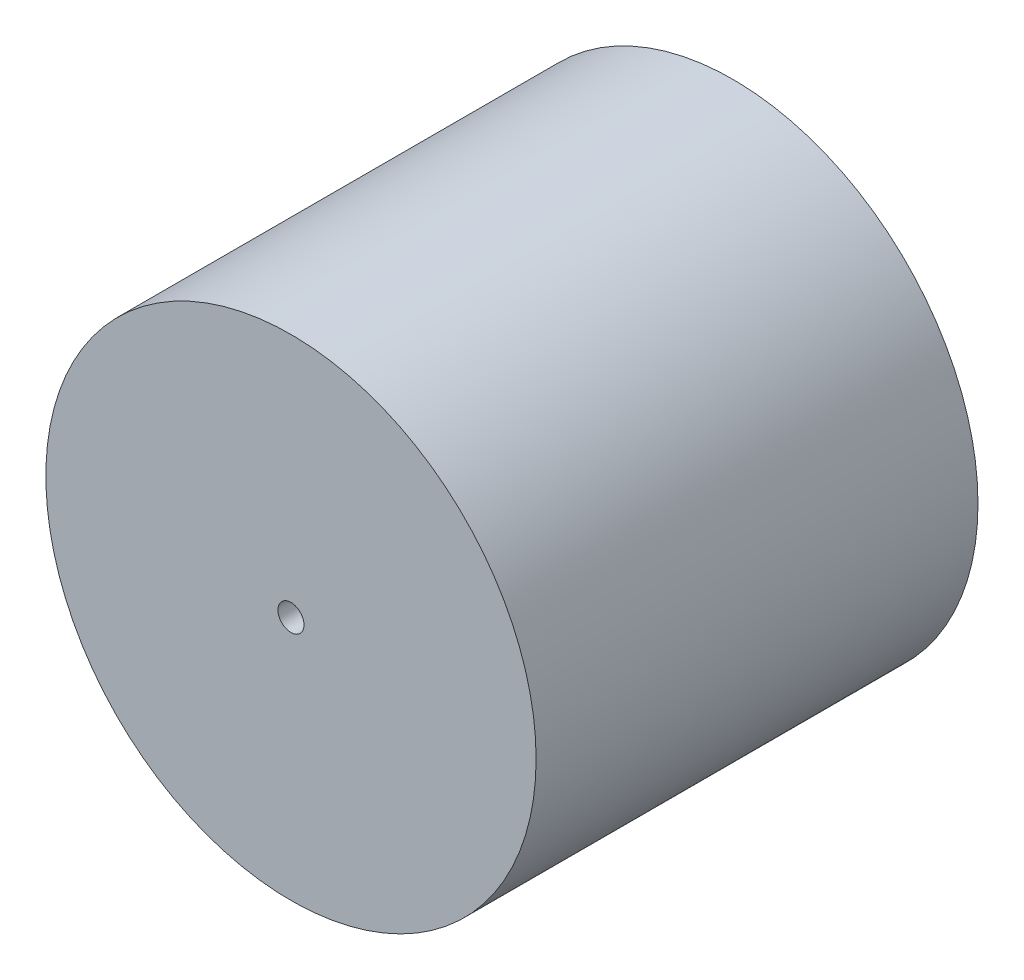
from build123d import *

# Parameters (mm, degrees)
SKETCH1_R                  = 38
BOSS_EXTRUDE1_DEPTH        = 68.5
SKETCH3_R                  = 20.5
CUT_EXTRUDE1_DEPTH         = 2
SKETCH4_R                  = 11
BOSS_EXTRUDE3_DEPTH        = 6.35
CHAMFER1_SIZE              = 4.35
CHAMFER1_SIZE2             = 3.916757593
F_10_32_TAPPED_HOLE1_D     = 4.0386
F_10_32_TAPPED_HOLE1_DEPTH = 5.6
F_10_32_TAPPED_HOLE1_TIP   = 1.213317848
F_10_32_TAPPED_HOLE2_D     = 4.0386
F_10_32_TAPPED_HOLE2_DEPTH = 13
F_10_32_TAPPED_HOLE2_TIP   = 1.213317848


with BuildPart() as part:
    # Sketch1 → Boss-Extrude1 (new body)
    with BuildSketch(Plane.XY):
        Circle(SKETCH1_R)
    extrude(amount=BOSS_EXTRUDE1_DEPTH)

    # Sketch3 → Cut-Extrude1 (cut)
    with BuildSketch(Plane(origin=(0, 0, 0), x_dir=(-1, 0, 0), z_dir=(0, 0, -1))):
        Circle(SKETCH3_R)
    extrude(amount=-CUT_EXTRUDE1_DEPTH, mode=Mode.SUBTRACT)

    # Sketch4 → Boss-Extrude3 (add)
    with BuildSketch(Plane.XY.offset(2)):
        Circle(SKETCH4_R)
    extrude(amount=-BOSS_EXTRUDE3_DEPTH)

    # Chamfer1
    chamfer1_edges = [part.edges().sort_by_distance(p)[0] for p in [
        (-11, 0, -4.35),
    ]]
    chamfer1_side = [part.faces().sort_by_distance(p)[0] for p in [
        (-11, 0, -1.175),
    ]]
    chamfer(chamfer1_edges, length=CHAMFER1_SIZE, length2=CHAMFER1_SIZE2, reference=chamfer1_side[0])

    # #10-32 Tapped Hole1
    with Locations(Plane.XY.offset(68.5)):
        with Locations((0, 0)):
            Hole(F_10_32_TAPPED_HOLE1_D / 2, depth=F_10_32_TAPPED_HOLE1_DEPTH)
            with Locations((0, 0, -(F_10_32_TAPPED_HOLE1_DEPTH + F_10_32_TAPPED_HOLE1_TIP / 2))):  # 118° drill point
                Cone(0, F_10_32_TAPPED_HOLE1_D / 2, F_10_32_TAPPED_HOLE1_TIP, mode=Mode.SUBTRACT)

    # #10-32 Tapped Hole2
    with Locations(Plane(origin=(0, 0, -4.35), x_dir=(-1, 0, 0), z_dir=(0, 0, -1))):
        with Locations((0, 0)):
            Hole(F_10_32_TAPPED_HOLE2_D / 2, depth=F_10_32_TAPPED_HOLE2_DEPTH)
            with Locations((0, 0, -(F_10_32_TAPPED_HOLE2_DEPTH + F_10_32_TAPPED_HOLE2_TIP / 2))):  # 118° drill point
                Cone(0, F_10_32_TAPPED_HOLE2_D / 2, F_10_32_TAPPED_HOLE2_TIP, mode=Mode.SUBTRACT)


solid = part.part
